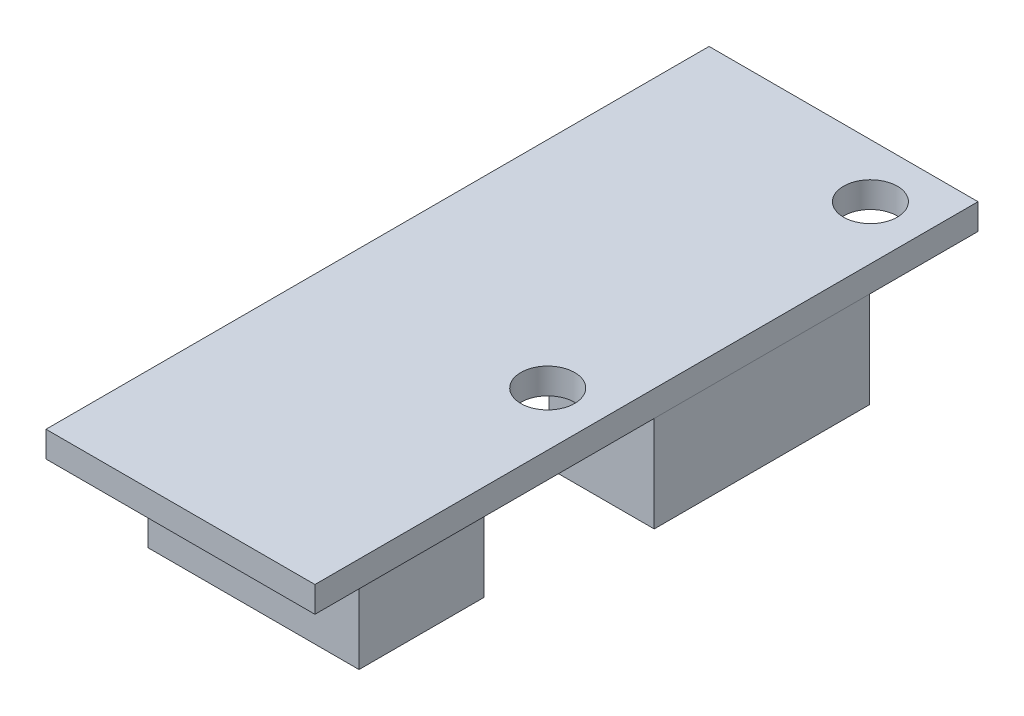
from build123d import *

# Parameters (mm, degrees)
SKETCH1_W           = 15.875
SKETCH1_H           = 39.1414
BOSS_EXTRUDE1_DEPTH = 1.524
SKETCH1_4_W         = 6.223
SKETCH1_4_H         = 12.7
BOSS_EXTRUDE2_DEPTH = 1.524
SKETCH1_5_W         = 6.223
SKETCH1_5_H         = 12.7
BOSS_EXTRUDE3_DEPTH = 5.715
SKETCH2_W           = 12.446
SKETCH2_H           = 7.366
BOSS_EXTRUDE4_DEPTH = 5.842


with BuildPart() as part:
    # Sketch1 → Boss-Extrude1 (new body)
    with BuildSketch(Plane(origin=(0, 0, 0), x_dir=(1, 0, 0), z_dir=(0, 1, 0))):
        with Locations((0, 2.6543)):
            Rectangle(SKETCH1_W, SKETCH1_H)
        with BuildLine():
            ThreePointArc((6.35, 0), (3.639967985, -1.122532015), (4.7625, 1.5875))
            ThreePointArc((4.7625, 1.5875), (5.885032015, 1.122532015), (6.35, 0))
        make_face(mode=Mode.SUBTRACT)
        Polygon((1.651, 15.875), (4.7625, 15.875), (7.874, 15.875), (7.874, 3.175), (4.7625, 3.175), (1.651, 3.175), align=None, mode=Mode.SUBTRACT)
        with BuildLine():
            ThreePointArc((6.35, 19.05), (5.885032015, 17.927467985), (4.7625, 17.4625))
            ThreePointArc((4.7625, 17.4625), (3.639967985, 20.172532015), (6.35, 19.05))
        make_face(mode=Mode.SUBTRACT)
    extrude(amount=BOSS_EXTRUDE1_DEPTH)

    # Sketch1_4 → Boss-Extrude2 (add)
    with BuildSketch(Plane(origin=(0, 0, 0), x_dir=(1, 0, 0), z_dir=(0, 1, 0))):
        with Locations((4.7625, 9.525)):
            Rectangle(SKETCH1_4_W, SKETCH1_4_H)
    extrude(amount=BOSS_EXTRUDE2_DEPTH)

    # Sketch1_5 → Boss-Extrude3 (add)
    with BuildSketch(Plane(origin=(0, 0, 0), x_dir=(1, 0, 0), z_dir=(0, 1, 0))):
        with Locations((4.7625, 9.525)):
            Rectangle(SKETCH1_5_W, SKETCH1_5_H)
    extrude(amount=-BOSS_EXTRUDE3_DEPTH)

    # Sketch2 → Boss-Extrude4 (add)
    with BuildSketch(Plane.XZ):
        with Locations((0, 8.9154)):
            Rectangle(SKETCH2_W, SKETCH2_H)
    extrude(amount=BOSS_EXTRUDE4_DEPTH)


solid = part.part
